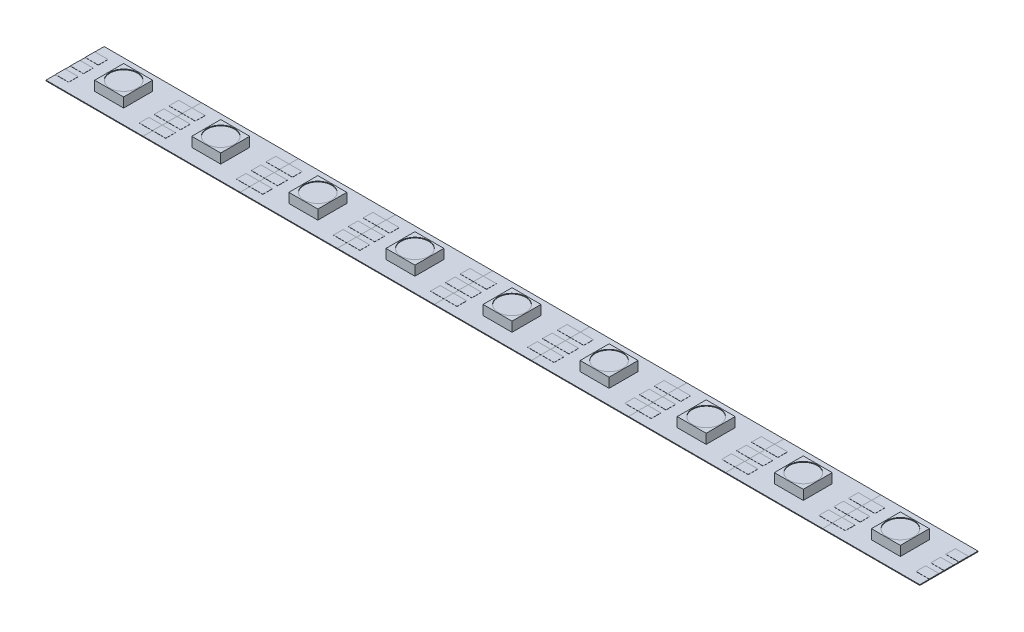
from build123d import *

# Parameters (mm, degrees)
SKETCH1_W           = 16.6116
SKETCH1_H           = 9.9568
BOSS_EXTRUDE1_DEPTH = 0.127
SKETCH3_W           = 4.953
SKETCH3_H           = 4.953
BOSS_EXTRUDE3_DEPTH = 1.651
SKETCH4_W           = 2.258810151
SKETCH4_H           = 1.651
BOSS_EXTRUDE4_DEPTH = 0.0254
SKETCH5_R           = 2.348345572
CUT_EXTRUDE1_DEPTH  = 0.127
LPATTERN1_COUNT     = 9
LPATTERN1_PITCH     = 16.6116


with BuildPart() as part:
    # Sketch1 → Boss-Extrude1 (new body)
    with BuildSketch(Plane(origin=(0, 0, 0), x_dir=(1, 0, 0), z_dir=(0, 1, 0))):
        Rectangle(SKETCH1_W, SKETCH1_H)
    extrude(amount=BOSS_EXTRUDE1_DEPTH)

    # Sketch3 → Boss-Extrude3 (add)
    with BuildSketch(Plane(origin=(0, 0.127, 0), x_dir=(1, 0, 0), z_dir=(0, 1, 0))):
        Rectangle(SKETCH3_W, SKETCH3_H)
    extrude(amount=BOSS_EXTRUDE3_DEPTH)

    # Sketch4 → Boss-Extrude4 (add)
    with BuildSketch(Plane(origin=(0, 0.127, 0), x_dir=(1, 0, 0), z_dir=(0, 1, 0))):
        with Locations((-7.176394925, 0)):
            Rectangle(SKETCH4_W, SKETCH4_H)
        with Locations((-7.176394925, 2.54)):
            Rectangle(SKETCH4_W, SKETCH4_H)
        with Locations((-7.176394925, -2.54)):
            Rectangle(SKETCH4_W, SKETCH4_H)
        with Locations((7.176394925, -2.54)):
            Rectangle(SKETCH4_W, SKETCH4_H)
        with Locations((7.176394925, 0)):
            Rectangle(SKETCH4_W, SKETCH4_H)
        with Locations((7.176394925, 2.54)):
            Rectangle(SKETCH4_W, SKETCH4_H)
    extrude(amount=BOSS_EXTRUDE4_DEPTH)

    # Sketch5 → Cut-Extrude1 (cut)
    with BuildSketch(Plane(origin=(0, 1.778, 0), x_dir=(1, 0, 0), z_dir=(0, 1, 0))):
        Circle(SKETCH5_R)
    extrude(amount=-CUT_EXTRUDE1_DEPTH, mode=Mode.SUBTRACT)


with BuildPart() as lpattern1_1:
    # LPattern1: pattern copy
    add(part.part.moved(Location(Vector(1, 0, 0) * (1 * LPATTERN1_PITCH))))


with BuildPart() as lpattern1_2:
    # LPattern1: pattern copy
    add(part.part.moved(Location(Vector(1, 0, 0) * (2 * LPATTERN1_PITCH))))


with BuildPart() as lpattern1_3:
    # LPattern1: pattern copy
    add(part.part.moved(Location(Vector(1, 0, 0) * (3 * LPATTERN1_PITCH))))


with BuildPart() as lpattern1_4:
    # LPattern1: pattern copy
    add(part.part.moved(Location(Vector(1, 0, 0) * (4 * LPATTERN1_PITCH))))


with BuildPart() as lpattern1_5:
    # LPattern1: pattern copy
    add(part.part.moved(Location(Vector(1, 0, 0) * (5 * LPATTERN1_PITCH))))


with BuildPart() as lpattern1_6:
    # LPattern1: pattern copy
    add(part.part.moved(Location(Vector(1, 0, 0) * (6 * LPATTERN1_PITCH))))


with BuildPart() as lpattern1_7:
    # LPattern1: pattern copy
    add(part.part.moved(Location(Vector(1, 0, 0) * (7 * LPATTERN1_PITCH))))


with BuildPart() as lpattern1_8:
    # LPattern1: pattern copy
    add(part.part.moved(Location(Vector(1, 0, 0) * (8 * LPATTERN1_PITCH))))


solid = Compound([part.part, lpattern1_1.part, lpattern1_2.part, lpattern1_3.part, lpattern1_4.part, lpattern1_5.part, lpattern1_6.part, lpattern1_7.part, lpattern1_8.part])
